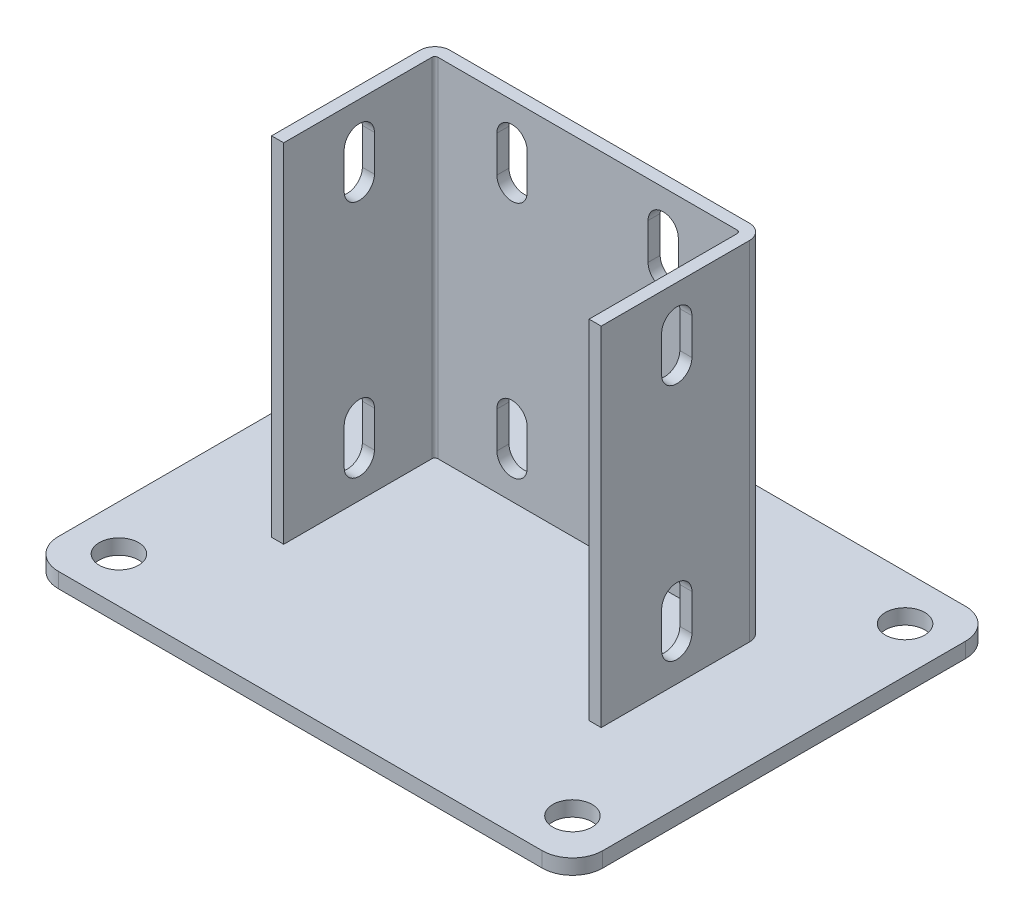
from build123d import *

# Parameters (mm, degrees)
SKETCH_2_W          = 180
SKETCH_2_H          = 140
EXTRUDE_1_DEPTH     = 5
EXTRUDE_1_2_DEPTH   = 115
EXTRUDE_2_DEPTH     = 2
CUT_EXTRUDE_1_DEPTH = 145.5
SKETCH_6_R          = 6.5
CUT_EXTRUDE_2_DEPTH = 6
FILLET_1_R          = 10
CUT_EXTRUDE_3_REACH = 101


with BuildPart() as part:
    # Эскиз2 → Extrude 1 (new body)
    with BuildSketch(Plane(origin=(0, 0, 0), x_dir=(1, 0, 0), z_dir=(0, 1, 0))):
        Rectangle(SKETCH_2_W, SKETCH_2_H)
    extrude(amount=EXTRUDE_1_DEPTH)

    # Эскиз3 → Extrude 1 2 (add)
    with BuildSketch(Plane(origin=(0, 5, 0), x_dir=(1, 0, 0), z_dir=(0, 1, 0))):
        with BuildLine():
            Line((-50.5, -25), (-50.5, 24))
            ThreePointArc((-50.5, 24), (-50.207106781, 24.707106781), (-49.5, 25))
            Line((-49.5, 25), (49.5, 25))
            ThreePointArc((49.5, 25), (50.207106781, 24.707106781), (50.5, 24))
            Line((50.5, 24), (50.5, -25))
            Line((50.5, -25), (54.5, -25))
            Line((54.5, -25), (54.5, 24))
            ThreePointArc((54.5, 24), (53.035533906, 27.535533906), (49.5, 29))
            Line((49.5, 29), (-49.5, 29))
            ThreePointArc((-49.5, 29), (-53.035533906, 27.535533906), (-54.5, 24))
            Line((-54.5, 24), (-54.5, -25))
            Line((-54.5, -25), (-50.5, -25))
        make_face()
    extrude(amount=EXTRUDE_1_2_DEPTH)

    # Эскиз4 → Бобышка-Вытянуть2 (add, symmetric)
    with BuildSketch(Plane(origin=(0, 0, 0), x_dir=(0, 0, -1), z_dir=(1, 0, 0))):
        Polygon((29, 67.353829072), (65, 5), (29, 5), align=None)
    extrude(amount=EXTRUDE_2_DEPTH, both=True)

    # Эскиз5 → Вырез-Вытянуть1 (cut, through all)
    with BuildSketch(Plane(origin=(54.5, 0, 0), x_dir=(0, 0, -1), z_dir=(1, 0, 0))):
        with BuildLine():
            Line((5, 108), (5, 96))
            ThreePointArc((5, 96), (0, 91), (-5, 96))
            Line((-5, 96), (-5, 108))
            ThreePointArc((-5, 108), (0, 113), (5, 108))
        make_face()
        with BuildLine():
            Line((5, 29), (5, 17))
            ThreePointArc((5, 17), (0, 12), (-5, 17))
            Line((-5, 17), (-5, 29))
            ThreePointArc((-5, 29), (0, 34), (5, 29))
        make_face()
    extrude(amount=-CUT_EXTRUDE_1_DEPTH, mode=Mode.SUBTRACT)

    # Эскиз6 → Вырез-Вытянуть2 (cut, through all)
    with BuildSketch(Plane(origin=(0, 5, 0), x_dir=(1, 0, 0), z_dir=(0, 1, 0))):
        with Locations(Location((-75, 55, 0), (0, 0, 270))):  # turned: the seam where the file's is
            Circle(SKETCH_6_R)
        with Locations(Location((-75, -55, 0), (0, 0, 270))):  # turned: the seam where the file's is
            Circle(SKETCH_6_R)
        with Locations(Location((75, 55, 0), (0, 0, 270))):  # turned: the seam where the file's is
            Circle(SKETCH_6_R)
        with Locations(Location((75, -55, 0), (0, 0, 270))):  # turned: the seam where the file's is
            Circle(SKETCH_6_R)
    extrude(amount=-CUT_EXTRUDE_2_DEPTH, mode=Mode.SUBTRACT)

    # Скругление1
    fillet_1_edges = [part.edges().sort_by_distance(p)[0] for p in [
        (90, 2.5, 70),
        (-90, 2.5, 70),
        (-90, 2.5, -70),
        (90, 2.5, -70),
    ]]
    fillet(fillet_1_edges, radius=FILLET_1_R)

    # Эскиз8 → Вырез-Вытянуть3 (cut, up to next)
    with BuildSketch(Plane(origin=(0, 0, -29), x_dir=(-1, 0, 0), z_dir=(0, 0, -1)), mode=Mode.PRIVATE) as cut_extrude_3_sk1:
        with BuildLine():
            Line((-20, 108), (-20, 96))
            ThreePointArc((-20, 96), (-25, 91), (-30, 96))
            Line((-30, 96), (-30, 108))
            ThreePointArc((-30, 108), (-25, 113), (-20, 108))
        make_face()
    cut_extrude_3_tool1 = extrude(cut_extrude_3_sk1.sketch, amount=-CUT_EXTRUDE_3_REACH, mode=Mode.PRIVATE) & part.part
    add(cut_extrude_3_tool1.solids().sort_by_distance((25, 102, -29))[0], mode=Mode.SUBTRACT)
    # Эскиз8 → Вырез-Вытянуть3 (cut, up to next)
    with BuildSketch(Plane(origin=(0, 0, -29), x_dir=(-1, 0, 0), z_dir=(0, 0, -1)), mode=Mode.PRIVATE) as cut_extrude_3_sk2:
        with BuildLine():
            Line((-20, 29), (-20, 17))
            ThreePointArc((-20, 17), (-25, 12), (-30, 17))
            Line((-30, 17), (-30, 29))
            ThreePointArc((-30, 29), (-25, 34), (-20, 29))
        make_face()
    cut_extrude_3_tool2 = extrude(cut_extrude_3_sk2.sketch, amount=-CUT_EXTRUDE_3_REACH, mode=Mode.PRIVATE) & part.part
    add(cut_extrude_3_tool2.solids().sort_by_distance((25, 23, -29))[0], mode=Mode.SUBTRACT)
    # Эскиз8 → Вырез-Вытянуть3 (cut, up to next)
    with BuildSketch(Plane(origin=(0, 0, -29), x_dir=(-1, 0, 0), z_dir=(0, 0, -1)), mode=Mode.PRIVATE) as cut_extrude_3_sk3:
        with BuildLine():
            Line((20, 108), (20, 96))
            ThreePointArc((20, 96), (25, 91), (30, 96))
            Line((30, 96), (30, 108))
            ThreePointArc((30, 108), (25, 113), (20, 108))
        make_face()
    cut_extrude_3_tool3 = extrude(cut_extrude_3_sk3.sketch, amount=-CUT_EXTRUDE_3_REACH, mode=Mode.PRIVATE) & part.part
    add(cut_extrude_3_tool3.solids().sort_by_distance((-25, 102, -29))[0], mode=Mode.SUBTRACT)
    # Эскиз8 → Вырез-Вытянуть3 (cut, up to next)
    with BuildSketch(Plane(origin=(0, 0, -29), x_dir=(-1, 0, 0), z_dir=(0, 0, -1)), mode=Mode.PRIVATE) as cut_extrude_3_sk4:
        with BuildLine():
            Line((20, 29), (20, 17))
            ThreePointArc((20, 17), (25, 12), (30, 17))
            Line((30, 17), (30, 29))
            ThreePointArc((30, 29), (25, 34), (20, 29))
        make_face()
    cut_extrude_3_tool4 = extrude(cut_extrude_3_sk4.sketch, amount=-CUT_EXTRUDE_3_REACH, mode=Mode.PRIVATE) & part.part
    add(cut_extrude_3_tool4.solids().sort_by_distance((-25, 23, -29))[0], mode=Mode.SUBTRACT)


solid = part.part
